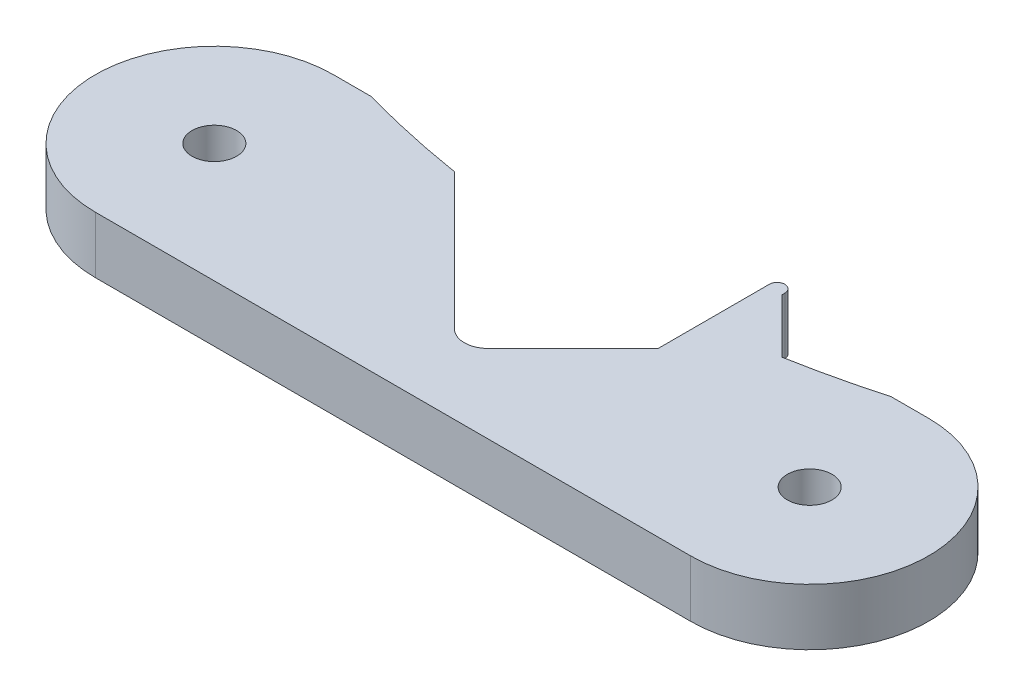
from build123d import *

# Parameters (mm, degrees)
SKETCH1_R           = 1.875
BOSS_EXTRUDE1_DEPTH = 4.7625
CUT_EXTRUDE1_DEPTH  = 5.7625
BOSS_EXTRUDE2_DEPTH = 4.7625


with BuildPart() as part:
    # Sketch1 → Boss-Extrude1 (new body)
    with BuildSketch(Plane(origin=(0, 0, 0), x_dir=(1, 0, 0), z_dir=(0, 1, 0))):
        with BuildLine():
            Line((-25, 5), (25, 5))
            ThreePointArc((25, 5), (35, -5), (25, -15))
            Line((25, -15), (-25, -15))
            ThreePointArc((-25, -15), (-35, -5), (-25, 5))
        make_face()
        with Locations((-25, -5)):
            Circle(SKETCH1_R, mode=Mode.SUBTRACT)
        with Locations((25, -5)):
            Circle(SKETCH1_R, mode=Mode.SUBTRACT)
    extrude(amount=BOSS_EXTRUDE1_DEPTH)

    # Sketch3 → Cut-Extrude1 (cut, through all)
    with BuildSketch(Plane(origin=(0, 4.7625, 0), x_dir=(1, 0, 0), z_dir=(0, 1, 0))):
        with BuildLine():
            Line((-12.855000529, 3.026573405), (-1.414213562, -8.414213562))
            ThreePointArc((-1.414213562, -8.414213562), (0, -9), (1.414213562, -8.414213562))
            Line((1.414213562, -8.414213562), (12.855000529, 3.026573405))
            ThreePointArc((12.855000529, 3.026573405), (0, 164), (-12.855000529, 3.026573405))
        make_face()
    extrude(amount=-CUT_EXTRUDE1_DEPTH, mode=Mode.SUBTRACT)

    # Sketch4 → Boss-Extrude2 (add)
    with BuildSketch(Plane(origin=(0, 4.7625, 0), x_dir=(1, 0, 0), z_dir=(0, 1, 0))):
        with BuildLine():
            Line((14.377657426, 3.286243553), (8.551135427, -1.277291698))
            Line((8.551135427, -1.277291698), (8.551135427, 8.062765551))
            ThreePointArc((8.551135427, 8.062765551), (9.201135427, 8.712765551), (9.851135427, 8.062765551))
            Line((9.851135427, 8.062765551), (9.851135427, 7.812765551))
            Line((9.851135427, 7.812765551), (14.377657426, 3.286243553))
        make_face()
    extrude(amount=-BOSS_EXTRUDE2_DEPTH)


solid = part.part
